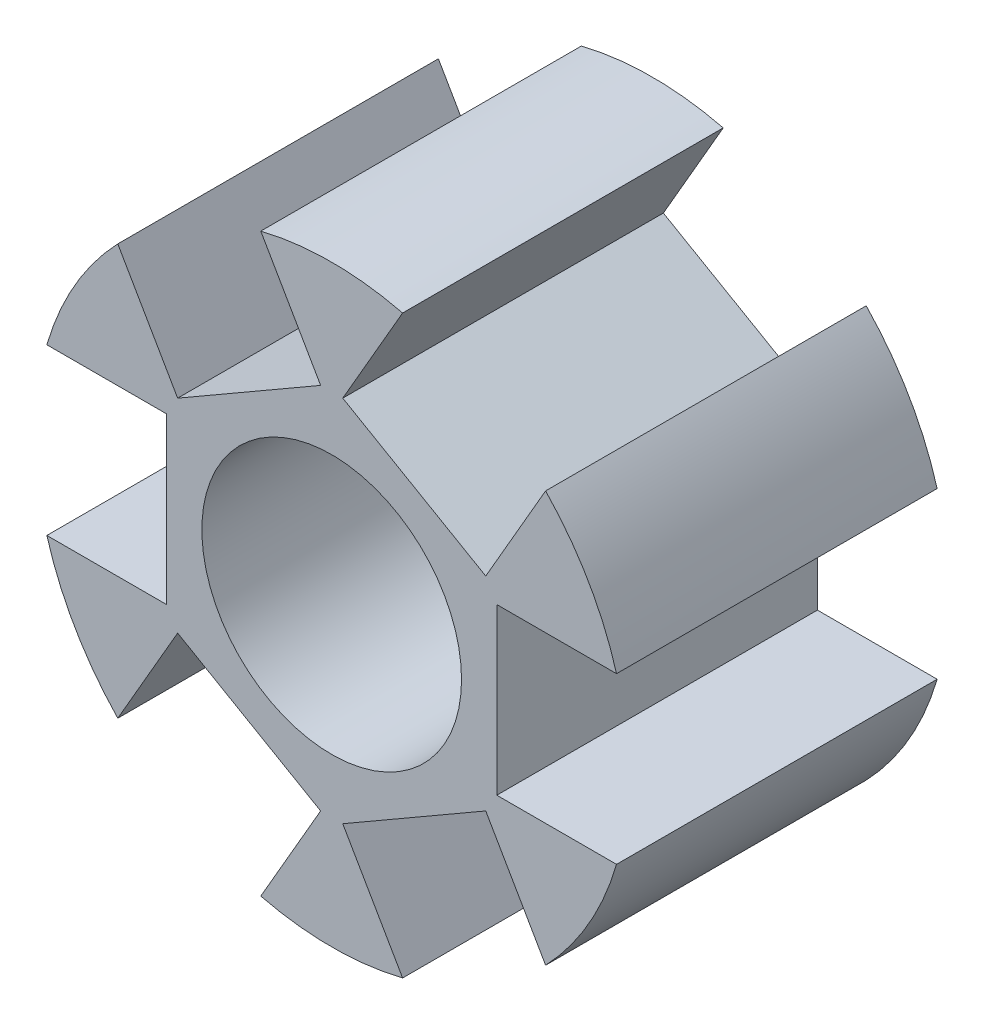
from build123d import *

# Parameters (mm, degrees)
SKETCH1_R           = 9.25
SKETCH1_R_2         = 4.05
BOSS_EXTRUDE1_DEPTH = 5
SKETCH2_W           = 5.15
SKETCH2_H           = 10
CUT_EXTRUDE3_DEPTH  = 4.1
CIRPATTERN1_COUNT   = 6


with BuildPart() as part:
    # Sketch1 → Boss-Extrude1 (new, symmetric)
    with BuildSketch(Plane.XY):
        Circle(SKETCH1_R)
        Circle(SKETCH1_R_2, mode=Mode.SUBTRACT)
    extrude(amount=BOSS_EXTRUDE1_DEPTH, both=True)

    # Sketch2 → Cut-Extrude3 (cut)
    with BuildSketch(Plane(origin=(-9.25, -17.193061184, 0), x_dir=(0, -1, 0), z_dir=(1, 0, 0))):
        with Locations((-17.193061184, 0)):
            Rectangle(SKETCH2_W, SKETCH2_H)
    cut_extrude3 = extrude(amount=CUT_EXTRUDE3_DEPTH, mode=Mode.SUBTRACT)

    # CirPattern1: Cut-Extrude3 ×6 about axis
    cirpattern1_axis = Axis((0, 0, 5), (0, 0, 1))
    for i in range(1, CIRPATTERN1_COUNT):
        add(cut_extrude3.rotate(cirpattern1_axis, i * 360 / CIRPATTERN1_COUNT), mode=Mode.SUBTRACT)


solid = part.part
